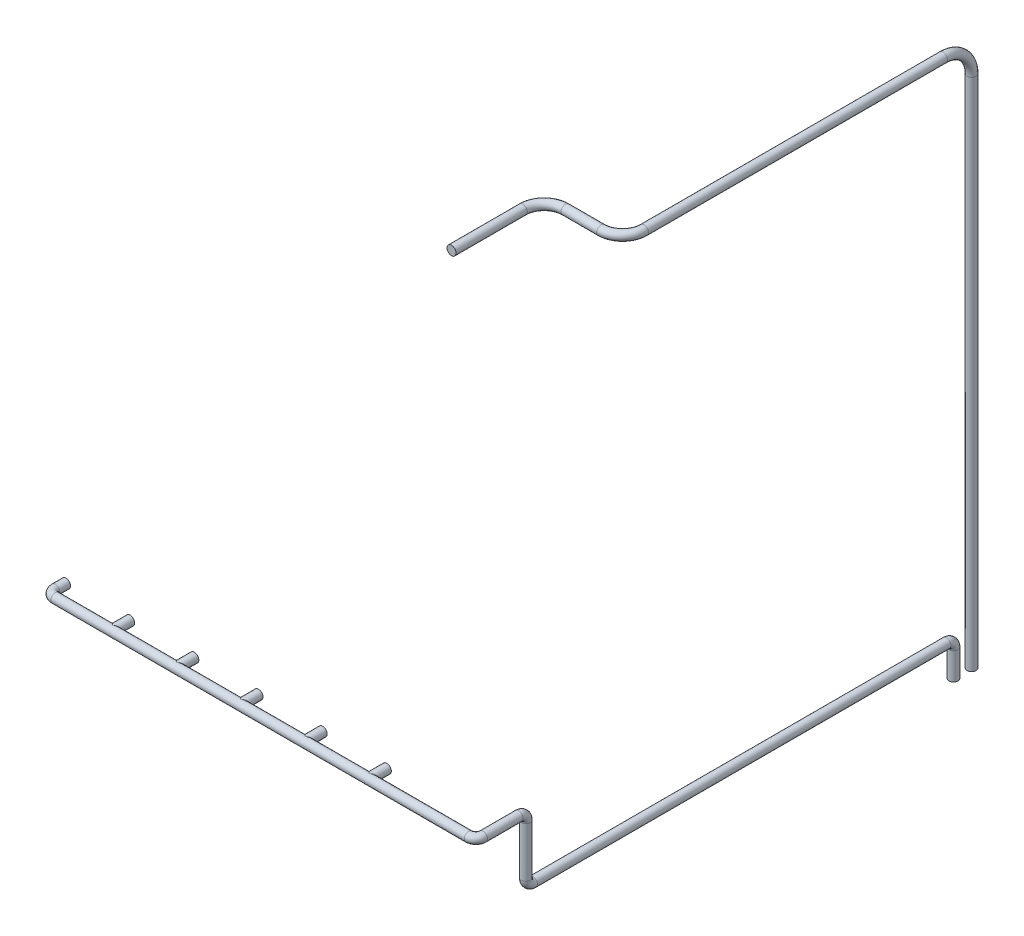
from build123d import *

# Parameters (mm, degrees)
CROQUIS1_R                = 63.5
SALIENTE_EXTRUIR1_DEPTH   = 50
SALIENTE_EXTRUIR1_2_DEPTH = 50
SALIENTE_EXTRUIR1_3_DEPTH = 50
SALIENTE_EXTRUIR1_4_DEPTH = 50
SALIENTE_EXTRUIR1_5_DEPTH = 50
SALIENTE_EXTRUIR1_6_DEPTH = 50
CROQUIS2_R                = 63.5
CROQUIS3_R                = 63.5
SALIENTE_EXTRUIR2_DEPTH   = 200
CROQUIS4_R                = 63.5
SALIENTE_EXTRUIR3_DEPTH   = 200
CROQUIS5_R                = 63.5
SALIENTE_EXTRUIR4_DEPTH   = 200
CROQUIS6_R                = 63.5
SALIENTE_EXTRUIR5_DEPTH   = 200
CROQUIS7_R                = 63.5
SALIENTE_EXTRUIR6_DEPTH   = 200
CROQUIS8_R                = 63.5
SALIENTE_EXTRUIR7_DEPTH   = 100
CROQUIS9_R                = 63.5


with BuildPart() as part:
    # Croquis1 → Saliente-Extruir1 (new body)
    with BuildSketch(Plane.XY):
        with Locations((63.5, 0)):
            Circle(CROQUIS1_R)
    extrude(amount=SALIENTE_EXTRUIR1_DEPTH)

    # Barrer1: sweep along a curve in space
    with BuildLine() as barrer1_path:
        Line((63.5, 0, 50), (63.5, 0, 150))
        ThreePointArc((63.5, 0, 150), (92.789321881, 0, 220.710678119), (163.5, 0, 250))
        Line((163.5, 0, 250), (5963.5, 0, 250))
        ThreePointArc((5963.5, 0, 250), (6034.210678119, 0, 220.710678119), (6063.5, 0, 150))
        Line((6063.5, 0, 150), (6063.5, 0, -350))
        ThreePointArc((6063.5, 0, -350), (6063.5, -29.289321881, -420.710678119), (6063.5, -100, -450))
        Line((6063.5, -100, -450), (6063.5, -800, -450))
        ThreePointArc((6063.5, -800, -450), (6063.5, -870.710678119, -479.289321881), (6063.5, -900, -550))
        Line((6063.5, -900, -550), (6063.5, -900, -6350))
        ThreePointArc((6063.5, -900, -6350), (6063.5, -929.289321881, -6420.710678119), (6063.5, -1000, -6450))
        Line((6063.5, -1000, -6450), (6063.5, -1380, -6450))
    # Croquis2 → Barrer1 (sweep)
    with BuildSketch(Plane.XY.offset(50)):
        with Locations((63.5, 0)):
            Circle(CROQUIS2_R)
    sweep(path=barrer1_path.line)



with BuildPart() as body_2:
    # Croquis1 → Saliente-Extruir1 2 (new body)
    with BuildSketch(Plane.XY):
        with Locations((963.5, 0)):
            Circle(CROQUIS1_R)
    extrude(amount=SALIENTE_EXTRUIR1_2_DEPTH)


with BuildPart() as body_3:
    # Croquis1 → Saliente-Extruir1 3 (new body)
    with BuildSketch(Plane.XY):
        with Locations((1863.5, 0)):
            Circle(CROQUIS1_R)
    extrude(amount=SALIENTE_EXTRUIR1_3_DEPTH)


with BuildPart() as body_4:
    # Croquis1 → Saliente-Extruir1 4 (new body)
    with BuildSketch(Plane.XY):
        with Locations((2763.5, 0)):
            Circle(CROQUIS1_R)
    extrude(amount=SALIENTE_EXTRUIR1_4_DEPTH)


with BuildPart() as body_5:
    # Croquis1 → Saliente-Extruir1 5 (new body)
    with BuildSketch(Plane.XY):
        with Locations((3663.5, 0)):
            Circle(CROQUIS1_R)
    extrude(amount=SALIENTE_EXTRUIR1_5_DEPTH)


with BuildPart() as body_6:
    # Croquis1 → Saliente-Extruir1 6 (new body)
    with BuildSketch(Plane.XY):
        with Locations((4563.5, 0)):
            Circle(CROQUIS1_R)
    extrude(amount=SALIENTE_EXTRUIR1_6_DEPTH)


with BuildPart() as part_1:
    add(part.part)

    add(body_2.part)  # Saliente-Extruir2 merges body 2
    # Croquis3 → Saliente-Extruir2 (add)
    with BuildSketch(Plane.XY.offset(50)):
        with Locations((963.5, 0)):
            Circle(CROQUIS3_R)
    extrude(amount=SALIENTE_EXTRUIR2_DEPTH)


    add(body_3.part)  # Saliente-Extruir3 merges body 3
    # Croquis4 → Saliente-Extruir3 (add)
    with BuildSketch(Plane.XY.offset(50)):
        with Locations((1863.5, 0)):
            Circle(CROQUIS4_R)
    extrude(amount=SALIENTE_EXTRUIR3_DEPTH)


    add(body_4.part)  # Saliente-Extruir4 merges body 4
    # Croquis5 → Saliente-Extruir4 (add)
    with BuildSketch(Plane.XY.offset(50)):
        with Locations((2763.5, 0)):
            Circle(CROQUIS5_R)
    extrude(amount=SALIENTE_EXTRUIR4_DEPTH)


    add(body_5.part)  # Saliente-Extruir5 merges body 5
    # Croquis6 → Saliente-Extruir5 (add)
    with BuildSketch(Plane.XY.offset(50)):
        with Locations((3663.5, 0)):
            Circle(CROQUIS6_R)
    extrude(amount=SALIENTE_EXTRUIR5_DEPTH)


    add(body_6.part)  # Saliente-Extruir6 merges body 6
    # Croquis7 → Saliente-Extruir6 (add)
    with BuildSketch(Plane.XY.offset(50)):
        with Locations((4563.5, 0)):
            Circle(CROQUIS7_R)
    extrude(amount=SALIENTE_EXTRUIR6_DEPTH)


with BuildPart() as body_2_2:
    # Croquis8 → Saliente-Extruir7 (new body)
    with BuildSketch(Plane.XZ.offset(1380)):
        with Locations((6063.5, -6704)):
            Circle(CROQUIS8_R)
    extrude(amount=-SALIENTE_EXTRUIR7_DEPTH)

    # Barrer2: sweep along a curve in space
    with BuildLine() as barrer2_path:
        Line((6063.5, -1280, -6704), (6063.5, 5840, -6704))
        ThreePointArc((6063.5, 5840, -6704), (6063.5, 6122.842712475, -6586.842712475), (6063.5, 6240, -6304))
        Line((6063.5, 6240, -6304), (6063.5, 6240, -2107.720850113))
        ThreePointArc((6063.5, 6240, -2107.720850113), (5975.632034356, 6240, -1895.588815757), (5763.5, 6240, -1807.720850113))
        Line((5763.5, 6240, -1807.720850113), (5263.5, 6240, -1807.720850113))
        ThreePointArc((5263.5, 6240, -1807.720850113), (5051.367965644, 6240, -1719.852884469), (4963.5, 6240, -1507.720850113))
        Line((4963.5, 6240, -1507.720850113), (4963.5, 6240, -507.720850113))
    # Croquis9 → Barrer2 (sweep)
    with BuildSketch(Plane(origin=(0, -1280, 0), x_dir=(1, 0, 0), z_dir=(0, 1, 0))):
        with Locations((6063.5, 6704)):
            Circle(CROQUIS9_R)
    sweep(path=barrer2_path.line)


solid = Compound([part_1.part, body_2_2.part])
